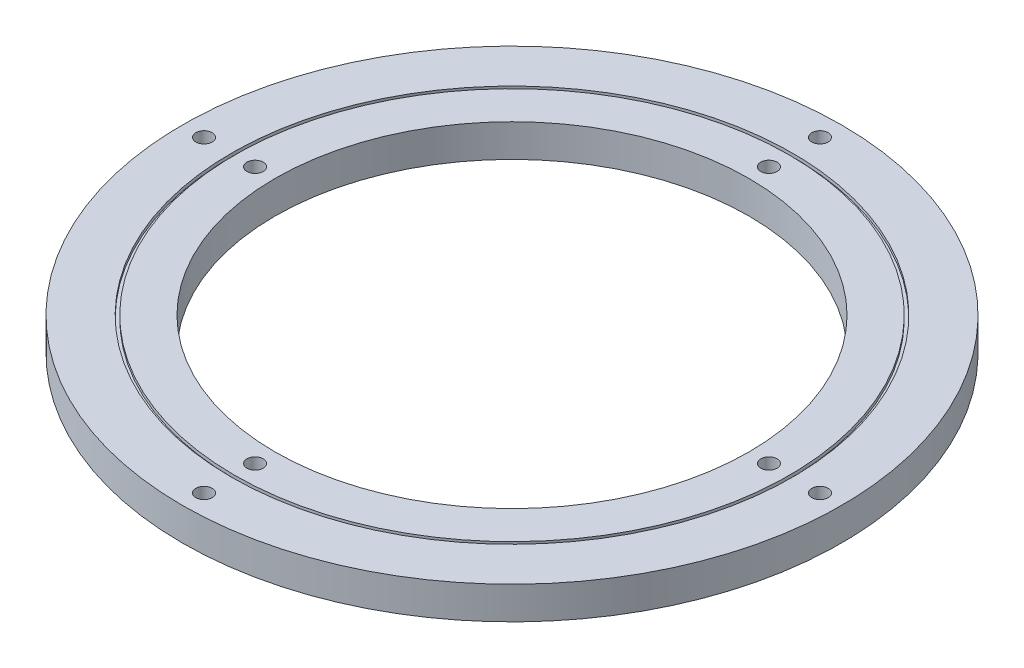
from build123d import *

# Parameters (mm, degrees)
SKETCH1_R           = 101.0285
SKETCH1_R_2         = 72.6313
BOSS_EXTRUDE1_DEPTH = 10
SKETCH2_R           = 2.5
CUT_EXTRUDE1_DEPTH  = 144.225401464
SKETCH3_R           = 86.0285
SKETCH3_R_2         = 85.0285
CUT_EXTRUDE2_DEPTH  = 1


with BuildPart() as part:
    # Sketch1 → Boss-Extrude1 (new body)
    with BuildSketch(Plane(origin=(0, 0, 0), x_dir=(1, 0, 0), z_dir=(0, 1, 0))):
        Circle(SKETCH1_R)
        Circle(SKETCH1_R_2, mode=Mode.SUBTRACT)
    extrude(amount=BOSS_EXTRUDE1_DEPTH)

    # Sketch2 → Cut-Extrude1 (cut, through all)
    with BuildSketch(Plane(origin=(0, 10, 0), x_dir=(1, 0, 0), z_dir=(0, 1, 0))):
        with Locations((-94.4137, 0)):
            Circle(SKETCH2_R)
        with Locations((-78.7635, 0)):
            Circle(SKETCH2_R)
        with Locations((0, 78.7635)):
            Circle(SKETCH2_R)
        with Locations((0, 94.4137)):
            Circle(SKETCH2_R)
        with Locations((78.7635, 0)):
            Circle(SKETCH2_R)
        with Locations((94.4137, 0)):
            Circle(SKETCH2_R)
        with Locations((0, -78.7635)):
            Circle(SKETCH2_R)
        with Locations((0, -94.4137)):
            Circle(SKETCH2_R)
    extrude(amount=-CUT_EXTRUDE1_DEPTH, mode=Mode.SUBTRACT)

    # Sketch3 → Cut-Extrude2 (cut)
    with BuildSketch(Plane(origin=(0, 10, 0), x_dir=(1, 0, 0), z_dir=(0, 1, 0))):
        Circle(SKETCH3_R)
        Circle(SKETCH3_R_2, mode=Mode.SUBTRACT)
    cut_extrude2 = extrude(amount=-CUT_EXTRUDE2_DEPTH, mode=Mode.SUBTRACT)

    # Mirror1: Cut-Extrude2 across plane
    add(cut_extrude2.mirror(Plane.ZX.offset(5)), mode=Mode.SUBTRACT)


solid = part.part
